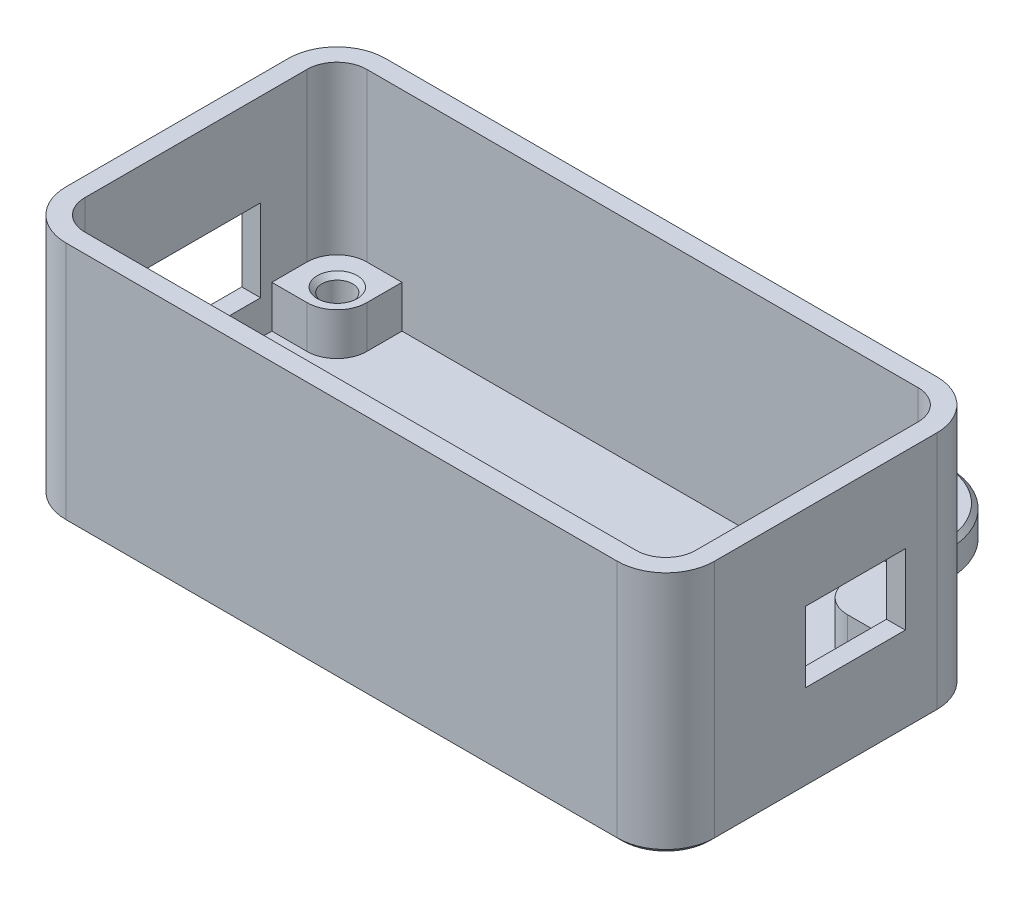
from build123d import *

# Parameters (mm, degrees)
BASE_DEPTH            = 3
WALLS_START           = 17.8
WALLS_DEPTH           = 17.8
PEDESTAL_DEPTH        = 3.6
SKETCH8_R             = 1.3
THRUHOLE_DEPTH        = 34.887460808
NUT_HOLE_DEPTH        = 2.4
MIRROR2_COPY_1_DEPTH  = 3.6
SKETCH6_R             = 3.05
EYELET_DEPTH          = 3
SKETCH4_W             = 11
SKETCH4_H             = 7
HOLE_USB_PORT_DEPTH   = 63.009354133
SKETCH5_W             = 8.5
SKETCH5_H             = 6
HOLE_SCREW_TERM_DEPTH = 63.009354133
CIRPATTERN1_COUNT     = 2
CHAMFER1_SIZE         = 0.4


with BuildPart() as part:
    # Sketch1 → base (new body)
    with BuildSketch(Plane(origin=(0, 0, 0), x_dir=(1, 0, 0), z_dir=(0, 1, 0))):
        with BuildLine():
            Line((-23.46, 13.6), (23.46, 13.6))
            ThreePointArc((23.46, 13.6), (26.387422074, 12.387422074), (27.6, 9.46))
            Line((27.6, 9.46), (27.6, -9.46))
            ThreePointArc((27.6, -9.46), (26.387422074, -12.387422074), (23.46, -13.6))
            Line((23.46, -13.6), (-23.46, -13.6))
            ThreePointArc((-23.46, -13.6), (-26.387422074, -12.387422074), (-27.6, -9.46))
            Line((-27.6, -9.46), (-27.6, 9.46))
            ThreePointArc((-27.6, 9.46), (-26.387422074, 12.387422074), (-23.46, 13.6))
        make_face()
    extrude(amount=-BASE_DEPTH)

    # Sketch1_3 → walls (add)
    with BuildSketch(Plane(origin=(0, 0, 0), x_dir=(1, 0, 0), z_dir=(0, 1, 0)).offset(WALLS_START)):
        with BuildLine():
            Line((23.46, 13.6), (-23.46, 13.6))
            ThreePointArc((-23.46, 13.6), (-26.387422074, 12.387422074), (-27.6, 9.46))
            Line((-27.6, 9.46), (-27.6, -9.46))
            ThreePointArc((-27.6, -9.46), (-26.387422074, -12.387422074), (-23.46, -13.6))
            Line((-23.46, -13.6), (23.46, -13.6))
            ThreePointArc((23.46, -13.6), (26.387422074, -12.387422074), (27.6, -9.46))
            Line((27.6, -9.46), (27.6, 9.46))
            ThreePointArc((27.6, 9.46), (26.387422074, 12.387422074), (23.46, 13.6))
        make_face()
        with BuildLine():
            Line((23.46, -12), (-23.46, -12))
            ThreePointArc((-23.46, -12), (-25.256051224, -11.256051224), (-26, -9.46))
            Line((-26, -9.46), (-26, 9.46))
            ThreePointArc((-26, 9.46), (-25.256051224, 11.256051224), (-23.46, 12))
            Line((-23.46, 12), (23.46, 12))
            ThreePointArc((23.46, 12), (25.256051224, 11.256051224), (26, 9.46))
            Line((26, 9.46), (26, -9.46))
            ThreePointArc((26, -9.46), (25.256051224, -11.256051224), (23.46, -12))
        make_face(mode=Mode.SUBTRACT)
    extrude(amount=-WALLS_DEPTH)

    # Sketch2 → pedestal (add)
    with BuildSketch(Plane(origin=(0, 0, 0), x_dir=(1, 0, 0), z_dir=(0, 1, 0))):
        with BuildLine():
            Line((-26, 6.46), (-23, 6.46))
            ThreePointArc((-23, 6.46), (-21.203948776, 7.203948776), (-20.46, 9))
            Line((-20.46, 9), (-20.46, 12))
            Line((-20.46, 12), (-26, 12))
            Line((-26, 12), (-26, 6.46))
        make_face()
    pedestal = extrude(amount=PEDESTAL_DEPTH)

    # Sketch8 → thruhole (cut, through all)
    with BuildSketch(Plane(origin=(0, 3.6, 0), x_dir=(1, 0, 0), z_dir=(0, 1, 0))):
        with Locations((-22.86, 8.89)):
            Circle(SKETCH8_R)
    thruhole = extrude(amount=-THRUHOLE_DEPTH, mode=Mode.SUBTRACT)

    # Sketch10 → nut hole (cut)
    with BuildSketch(Plane.XZ.offset(3)):
        Polygon((-25.8622214, -8.89), (-24.3611107, -11.49), (-21.3588893, -11.49), (-19.8577786, -8.89), (-21.3588893, -6.29), (-24.3611107, -6.29), align=None)
    nut_hole = extrude(amount=-NUT_HOLE_DEPTH, mode=Mode.SUBTRACT)

    # Mirror1: pedestal across plane
    add(pedestal.mirror(Plane(origin=(0, 0, 0), x_dir=(0, 0, 1), z_dir=(1, 0, 0))))

    # Mirror2: pedestal across plane
    add(pedestal.mirror(Plane.XY))

    # Mirror2 copy 1 sketch → Mirror2 copy 1 (add)
    with BuildSketch(Plane(origin=(0, 0, 0), x_dir=(-1, 0, 0), z_dir=(0, 1, 0))):
        with BuildLine():
            Line((-26, 6.46), (-23, 6.46))
            ThreePointArc((-23, 6.46), (-21.203948776, 7.203948776), (-20.46, 9))
            Line((-20.46, 9), (-20.46, 12))
            Line((-20.46, 12), (-26, 12))
            Line((-26, 12), (-26, 6.46))
        make_face()
    extrude(amount=MIRROR2_COPY_1_DEPTH)

    # Sketch6 → eyelet (add)
    with BuildSketch(Plane(origin=(0, -3, 0), x_dir=(1, 0, 0), z_dir=(0, 1, 0))):
        with BuildLine():
            Line((-18.5, 19.6), (-18.5, 13.6))
            Line((-18.5, 13.6), (-6.5, 13.6))
            Line((-6.5, 13.6), (-6.5, 19.6))
            ThreePointArc((-6.5, 19.6), (-12.5, 25.6), (-18.5, 19.6))
        make_face()
        with Locations((-12.5, 19.6)):
            Circle(SKETCH6_R, mode=Mode.SUBTRACT)
    eyelet = extrude(amount=EYELET_DEPTH)

    # Mirror3: eyelet across plane
    add(eyelet.mirror(Plane(origin=(0, 0, 0), x_dir=(0, 0, 1), z_dir=(1, 0, 0))))

    # Sketch4 → hole_USB_port (cut, through all)
    with BuildSketch(Plane(origin=(-26, 0, 0), x_dir=(0, 0, -1), z_dir=(1, 0, 0))):
        with Locations((0, 6.44)):
            Rectangle(SKETCH4_W, SKETCH4_H)
    extrude(amount=-HOLE_USB_PORT_DEPTH, mode=Mode.SUBTRACT)

    # Sketch5 → hole_screw_term (cut, through all)
    with BuildSketch(Plane.ZY.offset(-26)):
        with Locations((-2.53, 7.6)):
            Rectangle(SKETCH5_W, SKETCH5_H)
    extrude(amount=-HOLE_SCREW_TERM_DEPTH, mode=Mode.SUBTRACT)

    # CirPattern1: thruhole, nut hole ×2 about axis
    cirpattern1_axis = Axis((0, 18.84, 0), (0, -1, 0))
    add([thruhole.rotate(cirpattern1_axis, i * 360 / CIRPATTERN1_COUNT) for i in range(1, CIRPATTERN1_COUNT)], mode=Mode.SUBTRACT)
    add([nut_hole.rotate(cirpattern1_axis, i * 360 / CIRPATTERN1_COUNT) for i in range(1, CIRPATTERN1_COUNT)], mode=Mode.SUBTRACT)

    # Chamfer1
    chamfer1_edges = [part.edges().sort_by_distance(p)[0] for p in [
        (15.55, -3, -19.6),
        (-15.55, -3, -19.6),
        (-27.6, -3, 0),
        (-26.387422074, -3, 12.387422074),
        (0, -3, 13.6),
        (26.387422074, -3, 12.387422074),
        (27.6, -3, 0),
        (26.387422074, -3, -12.387422074),
        (20.98, -3, -13.6),
        (18.5, -3, -16.6),
        (12.5, -3, -25.6),
        (6.5, -3, -16.6),
        (0, -3, -13.6),
        (-6.5, -3, -16.6),
        (-12.5, -3, -25.6),
        (-18.5, -3, -16.6),
        (-20.98, -3, -13.6),
        (-26.387422074, -3, -12.387422074),
        (-25.11166605, -3, -10.19),
        (-22.86, -3, -11.49),
        (-20.60833395, -3, -10.19),
        (-20.60833395, -3, -7.59),
        (-22.86, -3, -6.29),
        (-25.11166605, -3, -7.59),
        (-24.16, 3.6, -8.89),
        (-18.5, 0, -16.6),
        (-12.5, 0, -25.6),
        (-6.5, 0, -16.6),
        (6.5, 0, -16.6),
        (12.5, 0, -25.6),
        (18.5, 0, -16.6),
        (-15.55, 0, -19.6),
        (15.55, 0, -19.6),
        (25.11166605, -3, 10.19),
        (22.86, -3, 11.49),
        (20.60833395, -3, 10.19),
        (20.60833395, -3, 7.59),
        (22.86, -3, 6.29),
        (25.11166605, -3, 7.59),
        (24.16, 3.6, 8.89),
    ]]
    chamfer(chamfer1_edges, length=CHAMFER1_SIZE)


solid = part.part
